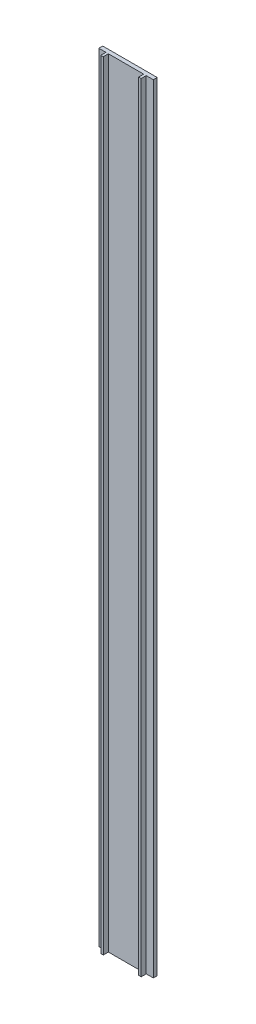
from build123d import *

# Parameters (mm, degrees)
SKETCH1_W           = 70
SKETCH1_H           = 1000
BOSS_EXTRUDE1_DEPTH = 5
SKETCH3_W           = 3.21
SKETCH3_H           = 1000
BOSS_EXTRUDE2_DEPTH = 6.5


with BuildPart() as part:
    # Sketch1 → Boss-Extrude1 (new body)
    with BuildSketch(Plane.XY):
        Rectangle(SKETCH1_W, SKETCH1_H)
    extrude(amount=BOSS_EXTRUDE1_DEPTH)

    # Sketch3 → Boss-Extrude2 (add)
    with BuildSketch(Plane.XY.offset(5)):
        with Locations((-24.3, 0)):
            Rectangle(SKETCH3_W, SKETCH3_H)
        with Locations((24.3, 0)):
            Rectangle(SKETCH3_W, SKETCH3_H)
    extrude(amount=BOSS_EXTRUDE2_DEPTH)


solid = part.part
